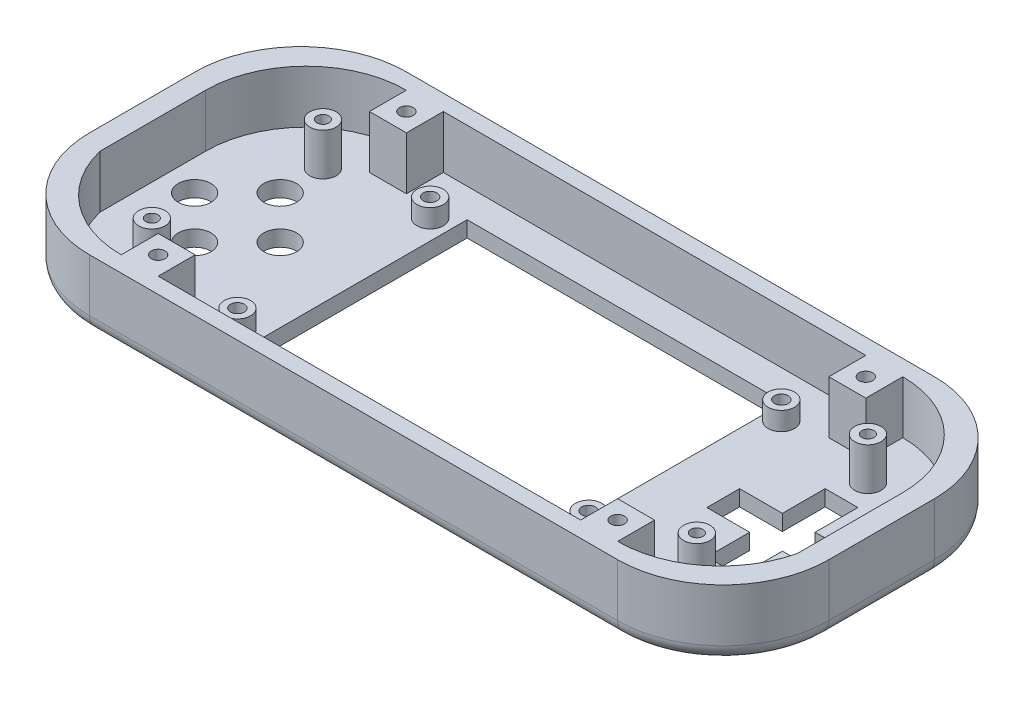
from build123d import *

# Parameters (mm, degrees)
BOSS_EXTRUDE1_DEPTH = 3
BOSS_EXTRUDE2_DEPTH = 10
SKETCH3_W           = 60
SKETCH3_H           = 43
CUT_EXTRUDE1_DEPTH  = 5
SKETCH4_R           = 2.5
BOSS_EXTRUDE3_DEPTH = 3.5
SKETCH5_R           = 1.3
CUT_EXTRUDE2_DEPTH  = 4.5
SKETCH6_R           = 1.3
CUT_EXTRUDE3_DEPTH  = 4.5
SKETCH7_R           = 1.3
CUT_EXTRUDE4_DEPTH  = 4.5
SKETCH8_R           = 1.3
CUT_EXTRUDE5_DEPTH  = 4.5
SKETCH9_R           = 3.1
CUT_EXTRUDE6_DEPTH  = 4.5
SKETCH10_R          = 2.5
SKETCH10_R_2        = 1.15
BOSS_EXTRUDE4_DEPTH = 8
SKETCH12_W          = 7
SKETCH12_H          = 7
BOSS_EXTRUDE5_DEPTH = 10
FILLET1_R           = 3
SKETCH13_R          = 1.3
CUT_EXTRUDE7_DEPTH  = 9


with BuildPart() as part:
    # Sketch1 → Boss-Extrude1 (new body)
    with BuildSketch(Plane(origin=(0, 0, 0), x_dir=(1, 0, 0), z_dir=(0, 1, 0))):
        with BuildLine():
            Line((70, 10), (70, -10))
            ThreePointArc((70, -10), (64.142135624, -24.142135624), (50, -30))
            Line((50, -30), (-50, -30))
            ThreePointArc((-50, -30), (-64.142135624, -24.142135624), (-70, -10))
            Line((-70, -10), (-70, 10))
            ThreePointArc((-70, 10), (-64.142135624, 24.142135624), (-50, 30))
            Line((-50, 30), (50, 30))
            ThreePointArc((50, 30), (64.142135624, 24.142135624), (70, 10))
        make_face()
    extrude(amount=BOSS_EXTRUDE1_DEPTH)

    # Sketch2 → Boss-Extrude2 (add)
    with BuildSketch(Plane(origin=(0, 3, 0), x_dir=(1, 0, 0), z_dir=(0, 1, 0))):
        with BuildLine():
            Line((-50, 30), (50, 30))
            ThreePointArc((50, 30), (64.142135624, 24.142135624), (70, 10))
            Line((70, 10), (70, -10))
            ThreePointArc((70, -10), (64.142135624, -24.142135624), (50, -30))
            Line((50, -30), (-50, -30))
            ThreePointArc((-50, -30), (-64.142135624, -24.142135624), (-70, -10))
            Line((-70, -10), (-70, 10))
            ThreePointArc((-70, 10), (-64.142135624, 24.142135624), (-50, 30))
        make_face()
        with BuildLine():
            Line((-47, 27), (47, 27))
            ThreePointArc((47, 27), (60.435028843, 21.435028843), (66, 8))
            Line((66, 8), (66, -12))
            ThreePointArc((66, -12), (59.103718437, -22.798043353), (47, -27))
            Line((47, -27), (-47, -27))
            ThreePointArc((-47, -27), (-59.103718437, -22.798043353), (-66, -12))
            Line((-66, -12), (-66, 8))
            ThreePointArc((-66, 8), (-60.435028843, 21.435028843), (-47, 27))
        make_face(mode=Mode.SUBTRACT)
    extrude(amount=BOSS_EXTRUDE2_DEPTH)

    # Sketch3 → Cut-Extrude1 (cut)
    with BuildSketch(Plane(origin=(0, 3, 0), x_dir=(1, 0, 0), z_dir=(0, 1, 0))):
        Rectangle(SKETCH3_W, SKETCH3_H)
    extrude(amount=-CUT_EXTRUDE1_DEPTH, mode=Mode.SUBTRACT)

    # Sketch4 → Boss-Extrude3 (add)
    with BuildSketch(Plane(origin=(0, 3, 0), x_dir=(1, 0, 0), z_dir=(0, 1, 0))):
        with Locations((-33.75, 18.25)):
            Circle(SKETCH4_R)
        with Locations((-33.75, -18.25)):
            Circle(SKETCH4_R)
        with Locations((32.75, -18.25)):
            Circle(SKETCH4_R)
        with Locations((32.75, 18.25)):
            Circle(SKETCH4_R)
    extrude(amount=BOSS_EXTRUDE3_DEPTH)

    # Sketch5 → Cut-Extrude2 (cut)
    with BuildSketch(Plane(origin=(0, 6.5, 0), x_dir=(1, 0, 0), z_dir=(0, 1, 0))):
        with Locations((-33.75, -18.25)):
            Circle(SKETCH5_R)
    extrude(amount=-CUT_EXTRUDE2_DEPTH, mode=Mode.SUBTRACT)

    # Sketch6 → Cut-Extrude3 (cut)
    with BuildSketch(Plane(origin=(0, 6.5, 0), x_dir=(1, 0, 0), z_dir=(0, 1, 0))):
        with Locations((-33.75, 18.25)):
            Circle(SKETCH6_R)
    extrude(amount=-CUT_EXTRUDE3_DEPTH, mode=Mode.SUBTRACT)

    # Sketch7 → Cut-Extrude4 (cut)
    with BuildSketch(Plane(origin=(0, 6.5, 0), x_dir=(1, 0, 0), z_dir=(0, 1, 0))):
        with Locations((32.75, 18.25)):
            Circle(SKETCH7_R)
    extrude(amount=-CUT_EXTRUDE4_DEPTH, mode=Mode.SUBTRACT)

    # Sketch8 → Cut-Extrude5 (cut)
    with BuildSketch(Plane(origin=(0, 6.5, 0), x_dir=(1, 0, 0), z_dir=(0, 1, 0))):
        with Locations((32.75, -18.25)):
            Circle(SKETCH8_R)
    extrude(amount=-CUT_EXTRUDE5_DEPTH, mode=Mode.SUBTRACT)

    # Sketch9 → Cut-Extrude6 (cut)
    with BuildSketch(Plane(origin=(0, 3, 0), x_dir=(1, 0, 0), z_dir=(0, 1, 0))):
        with Locations((-44, 0.1)):
            Circle(SKETCH9_R)
        with Locations((-52.1, 8.2)):
            Circle(SKETCH9_R)
        with Locations((-60.2, 0.1)):
            Circle(SKETCH9_R)
        with Locations((-52.1, -8)):
            Circle(SKETCH9_R)
        Polygon((62.3, 3.2), (54.2, 3.2), (54.2, 5.1), (54.2, 11.3), (48, 11.3), (48, 5.1), (48, 3.2), (46.1, 3.2), (39.9, 3.2), (39.9, -3), (46.1, -3), (48, -3), (48, -4.9), (48, -11.1), (54.2, -11.1), (54.2, -4.9), (54.2, -3), (62.3, -3), align=None)
    extrude(amount=-CUT_EXTRUDE6_DEPTH, mode=Mode.SUBTRACT)

    # Sketch10 → Boss-Extrude4 (add)
    with BuildSketch(Plane(origin=(0, 3, 0), x_dir=(1, 0, 0), z_dir=(0, 1, 0))):
        with Locations((-52.1, -16.1)):
            Circle(SKETCH10_R)
        with Locations((-52.1, -16.1)):
            Circle(SKETCH10_R_2, mode=Mode.SUBTRACT)
        with Locations((-52.1, 16.3)):
            Circle(SKETCH10_R)
        with Locations((-52.1, 16.3)):
            Circle(SKETCH10_R_2, mode=Mode.SUBTRACT)
        with Locations((51.1, 16.3)):
            Circle(SKETCH10_R)
        with Locations((51.1, 16.3)):
            Circle(SKETCH10_R_2, mode=Mode.SUBTRACT)
        with Locations((51.1, -16.1)):
            Circle(SKETCH10_R)
        with Locations((51.1, -16.1)):
            Circle(SKETCH10_R_2, mode=Mode.SUBTRACT)
    extrude(amount=BOSS_EXTRUDE4_DEPTH)

    # Sketch12 → Boss-Extrude5 (add)
    with BuildSketch(Plane(origin=(0, 3, 0), x_dir=(1, 0, 0), z_dir=(0, 1, 0))):
        with Locations((-43.5, 23.5)):
            Rectangle(SKETCH12_W, SKETCH12_H)
        with Locations((-43.5, -23.5)):
            Rectangle(SKETCH12_W, SKETCH12_H)
        with Locations((43.5, -23.5)):
            Rectangle(SKETCH12_W, SKETCH12_H)
        with Locations((43.5, 23.5)):
            Rectangle(SKETCH12_W, SKETCH12_H)
    extrude(amount=BOSS_EXTRUDE5_DEPTH)

    # Fillet1
    fillet1_edges = [part.edges().sort_by_distance(p)[0] for p in [
        (70, 0, 0),
        (64.142135624, 0, 24.142135624),
        (0, 0, 30),
        (-64.142135624, 0, 24.142135624),
        (-70, 0, 0),
        (-64.142135624, 0, -24.142135624),
        (0, 0, -30),
        (64.142135624, 0, -24.142135624),
    ]]
    fillet(fillet1_edges, radius=FILLET1_R)

    # Sketch13 → Cut-Extrude7 (cut)
    with BuildSketch(Plane(origin=(0, 13, 0), x_dir=(1, 0, 0), z_dir=(0, 1, 0))):
        with Locations((-43.5, 23.5)):
            Circle(SKETCH13_R)
        with Locations((-43.5, -23.5)):
            Circle(SKETCH13_R)
        with Locations((43.5, -23.5)):
            Circle(SKETCH13_R)
        with Locations((43.5, 23.5)):
            Circle(SKETCH13_R)
    extrude(amount=-CUT_EXTRUDE7_DEPTH, mode=Mode.SUBTRACT)


solid = part.part
